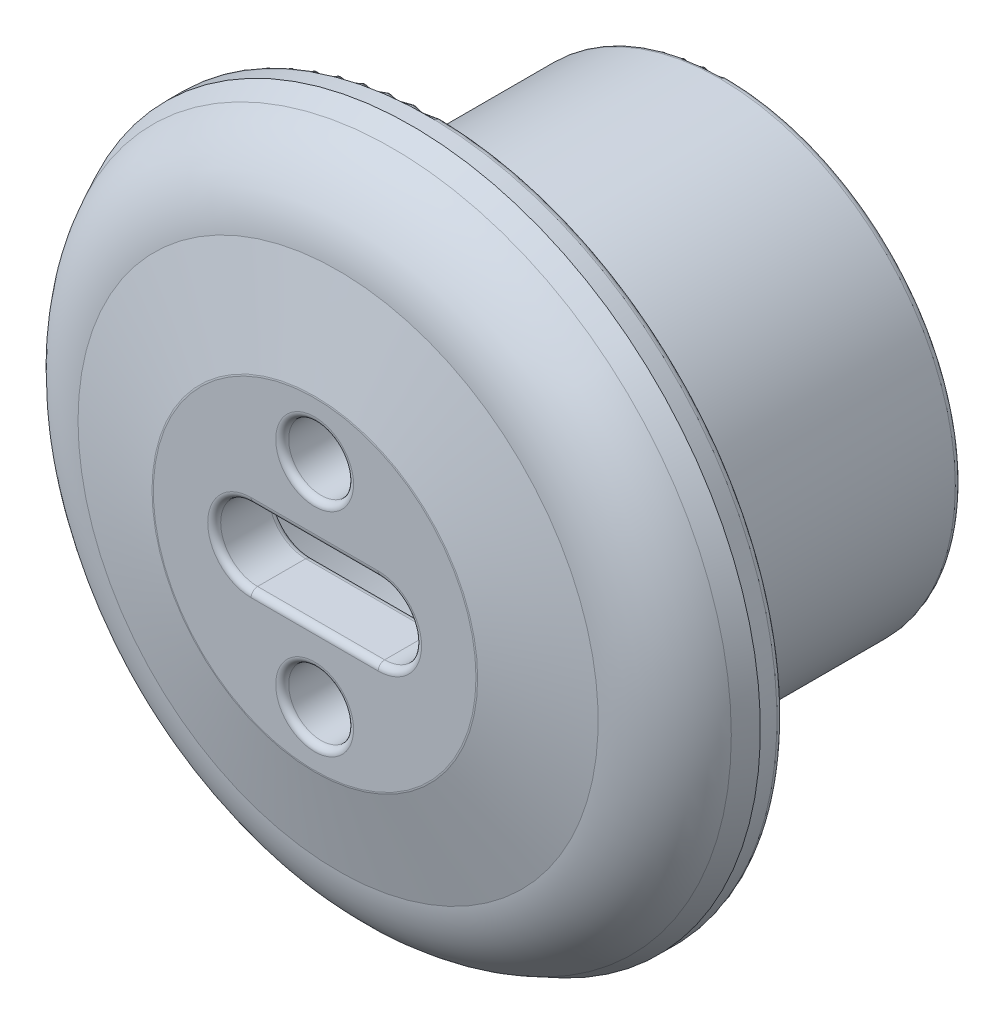
from build123d import *

# Parameters (mm, degrees)
FILLET2_R          = 0.2
SKETCH2_R          = 1
CUT_EXTRUDE1_DEPTH = 10
FILLET3_R          = 0.2


with BuildPart() as part:
    # Sketch1 → Revolve1 (revolve)
    with BuildSketch(Plane(origin=(0, 0, 0), x_dir=(0, 0, -1), z_dir=(1, 0, 0))):
        with BuildLine():
            Line((2.397152395, 10.455987944), (3, 10.75))
            Line((3, 10.75), (3.712206696, 10.75))
            Line((3.712206696, 10.75), (3.712206696, 8.75))
            Line((3.712206696, 8.75), (4.712206696, 8.75))
            Line((4.712206696, 8.75), (4.712206696, 7.25))
            Line((4.712206696, 7.25), (12.712206696, 7.25))
            Line((12.712206696, 7.25), (12.712206696, 6.25))
            Line((12.712206696, 6.25), (3.256669121, 6.25))
            Line((3.256669121, 6.25), (2.882509958, 6.25))
            ThreePointArc((2.882509958, 6.25), (2.175403177, 5.957106781), (1.882509958, 5.25))
            Line((1.882509958, 5.25), (1.882509958, 0))
            Line((1.882509958, 0), (0, 0))
            Line((0, 0), (0, 5))
            Line((0, 5), (0.723761069, 8.022622081))
            ThreePointArc((0.723761069, 8.022622081), (1.240295439, 9.459475411), (2.397152395, 10.455987944))
        make_face()
    revolve(axis=Axis((0, 0, -1.882509958), (0, 0, 1)))

    # Fillet2
    fillet2_edges = [part.edges().sort_by_distance(p)[0] for p in [
        (0, -6.25, -12.712206696),
        (0, -7.25, -12.712206696),
        (0, -8.75, -4.712206696),
        (0, -10.75, -3.712206696),
    ]]
    fillet(fillet2_edges, radius=FILLET2_R)

    # Sketch2 → Cut-Extrude1 (cut)
    with BuildSketch(Plane.XY):
        with Locations((0, 3.274424466)):
            Circle(SKETCH2_R)
        with Locations((0, -3.274424466)):
            Circle(SKETCH2_R)
        with BuildLine():
            Line((-1.959552245, 1.138245181), (1.959552245, 1.138245181))
            ThreePointArc((1.959552245, 1.138245181), (3.097797425, 0), (1.959552245, -1.138245181))
            Line((1.959552245, -1.138245181), (-1.959552245, -1.138245181))
            ThreePointArc((-1.959552245, -1.138245181), (-3.097797425, 0), (-1.959552245, 1.138245181))
        make_face()
    extrude(amount=-CUT_EXTRUDE1_DEPTH, mode=Mode.SUBTRACT)

    # Fillet3
    fillet3_edges = [part.edges().sort_by_distance(p)[0] for p in [
        (0, -5, 0),
        (0, -1.138245181, -1.882509958),
        (3.097797425, 0, -1.882509958),
        (0, 1.138245181, -1.882509958),
        (-3.097797425, 0, -1.882509958),
        (-1, -3.274424466, -1.882509958),
        (-1, -3.274424466, 0),
        (-1, 3.274424466, -1.882509958),
        (-1, 3.274424466, 0),
        (-3.097797425, 0, 0),
        (0, -1.138245181, 0),
        (3.097797425, 0, 0),
        (0, 1.138245181, 0),
    ]]
    fillet(fillet3_edges, radius=FILLET3_R)


solid = part.part
